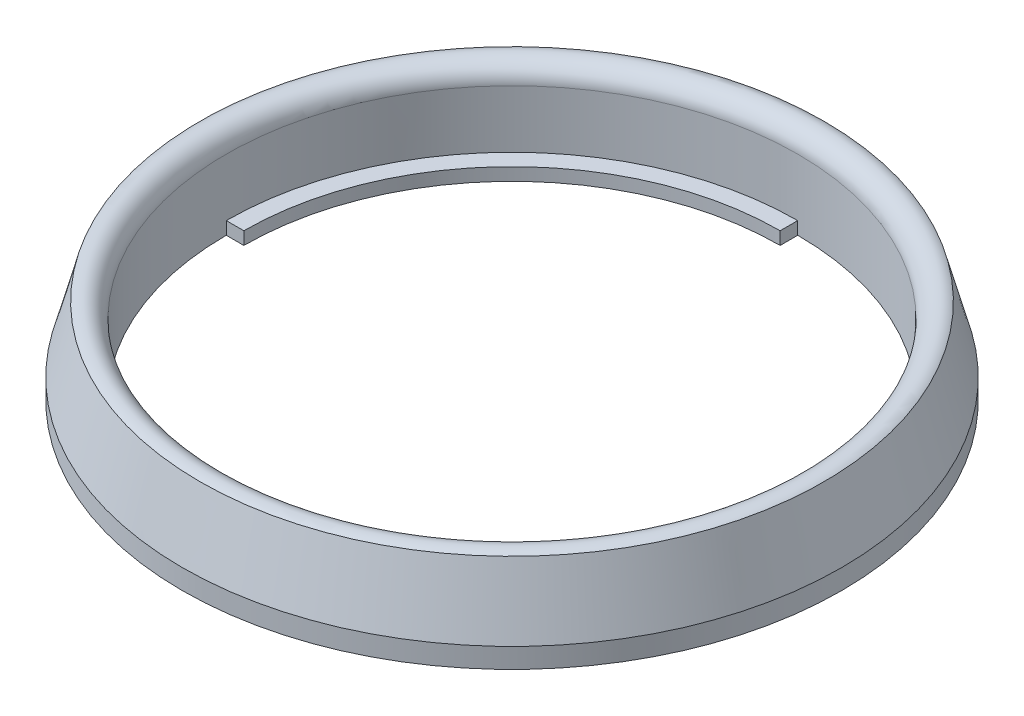
from build123d import *

# Parameters (mm, degrees)
CUT_EXTRUDE2_DEPTH = 11.0000001


with BuildPart() as part:
    # Sketch1 → Revolve1 (revolve)
    with BuildSketch(Plane.XY, mode=Mode.PRIVATE) as revolve1_sk:
        with BuildLine():
            Line((37.5, 0), (30.5, 0))
            Line((30.5, 0), (30.5, 1.45))
            Line((30.5, 1.45), (32.5, 1.45))
            Line((32.5, 1.45), (32.5, 8))
            ThreePointArc((32.5, 8), (33.5, 9.732050808), (35.5, 9.732050808))
            Line((35.5, 9.732050808), (37.5, 2.267949192))
            Line((37.5, 2.267949192), (37.5, 0))
        make_face()
    revolve(revolve1_sk.sketch.rotate(Axis((0, 0, 0), (0, 1, 0)), 90), axis=Axis((0, 0, 0), (0, 1, 0)))  # turned: the seam where the file's is

    # Sketch2 → Cut-Extrude2 (cut, through all)
    with BuildSketch(Plane(origin=(0, 0, 0), x_dir=(1, 0, 0), z_dir=(0, 1, 0))):
        with BuildLine():
            Line((0, 30.5), (0, 32.5))
            ThreePointArc((0, 32.5), (22.980970389, 22.980970389), (32.5, 0))
            Line((32.5, 0), (30.5, 0))
            ThreePointArc((30.5, 0), (21.566756826, 21.566756826), (0, 30.5))
        make_face()
        with BuildLine():
            Line((0, -32.5), (0, -30.5))
            ThreePointArc((0, -30.5), (-21.566756826, -21.566756826), (-30.5, 0))
            Line((-30.5, 0), (-32.5, 0))
            ThreePointArc((-32.5, 0), (-22.980970389, -22.980970389), (0, -32.5))
        make_face()
    extrude(amount=CUT_EXTRUDE2_DEPTH, mode=Mode.SUBTRACT)


solid = part.part
